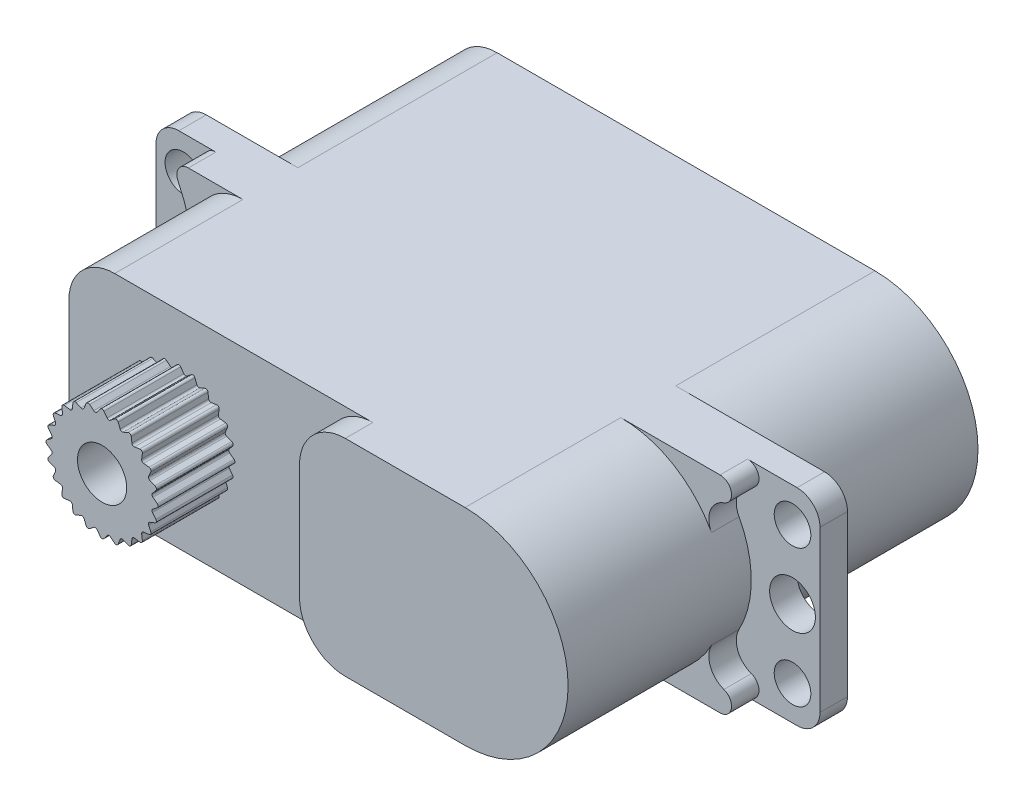
from build123d import *

# Parameters (mm, degrees)
SKETCH_1_W                    = 29
SKETCH_1_H                    = 17.9
EXTRUDE_1_DEPTH               = 9
CUT_EXTRUDE_1_DEPTH           = 8
SKETCH_3_W                    = 3
SKETCH_3_H                    = 8
CUT_EXTRUDE_2_DEPTH           = 10
EXTRUDE_2_DEPTH               = 1.2
EXTRUDE_3_DEPTH               = 1.2
EXTRUDE_4_DEPTH               = 1.2
EXTRUDE_5_DEPTH               = 1.2
SKETCH_8_W                    = 11.270245309
SKETCH_8_H                    = 1.2
CUT_EXTRUDE_3_DEPTH           = 10
CUT_EXTRUDE_4_DEPTH           = 8.7
SKETCH_10_W                   = 3
SKETCH_10_H                   = 8.7
CUT_EXTRUDE_5_DEPTH           = 10
EXTRUDE_6_DEPTH               = 3.35
HOLE_WIZARD_4_9_4_9_1_D       = 4.9
HOLE_WIZARD_4_9_4_9_1_DEPTH   = 8.7
HOLE_WIZARD_2_0_2_1_D         = 2
HOLE_WIZARD_2_0_2_1_DEPTH     = 11.35
HOLE_WIZARD_1_6_1_6_1_D       = 1.6
HOLE_WIZARD_1_6_1_6_1_DEPTH   = 11.35
HOLE_WIZARD_2_15_2_15_1_D     = 2.15
HOLE_WIZARD_2_15_2_15_1_DEPTH = 4.05
HOLE_WIZARD_2_15_2_15_1_TIP   = 0.645925165
FILLET_1_R                    = 0.1
FILLET_2_R                    = 1
FILLET_3_R                    = 2


with BuildPart() as part:
    # 草图1 → 凸台-拉伸1 (new body)
    with BuildSketch(Plane(origin=(0, 4.5, 0), x_dir=(1, 0, 0), z_dir=(0, 1, 0))):
        with Locations((6.7, 0.95)):
            Rectangle(SKETCH_1_W, SKETCH_1_H)
    extrude(amount=-EXTRUDE_1_DEPTH)

    # 草图2 → 切除-拉伸1 (cut)
    with BuildSketch(Plane.XY.offset(8)):
        with BuildLine():
            Line((13.7, -4.5), (21.2, -4.5))
            Line((21.2, -4.5), (21.2, 4.5))
            Line((21.2, 4.5), (13.7, 4.5))
            ThreePointArc((13.7, 4.5), (18.2, 0), (13.7, -4.5))
        make_face()
    extrude(amount=-CUT_EXTRUDE_1_DEPTH, mode=Mode.SUBTRACT)

    # 草图3 → 切除-拉伸2 (cut, through all)
    with BuildSketch(Plane(origin=(0, 4.5, 0), x_dir=(-1, 0, 0), z_dir=(0, 1, 0))):
        with Locations((6.3, 4)):
            Rectangle(SKETCH_3_W, SKETCH_3_H)
    extrude(amount=-CUT_EXTRUDE_2_DEPTH, mode=Mode.SUBTRACT)

    # 草图4 → 凸台-拉伸2 (add)
    with BuildSketch(Plane.XY):
        with BuildLine():
            Line((-4.8, 4.5), (-4.8, 0.09919776))
            ThreePointArc((-4.8, 0.09919776), (-5.011332605, 1.988549506), (-5.634884808, 3.78451558))
            ThreePointArc((-5.634884808, 3.78451558), (-5.606632964, 4.266700009), (-5.183701403, 4.5))
            Line((-5.183701403, 4.5), (-4.8, 4.5))
        make_face()
    extrude(amount=EXTRUDE_2_DEPTH)

    # 草图5 → 凸台-拉伸3 (add)
    with BuildSketch(Plane.XY):
        with BuildLine():
            Line((13.7, 4.5), (18.036138266, 4.5))
            ThreePointArc((18.036138266, 4.5), (18.528949615, 4.084480614), (18.202670288, 3.528547897))
            ThreePointArc((18.202670288, 3.528547897), (17.611520628, 2.954458719), (17.662886698, 2.132024629))
            ThreePointArc((17.662886698, 2.132024629), (16.008234083, 3.862907637), (13.7, 4.5))
        make_face()
    extrude(amount=EXTRUDE_3_DEPTH)

    # 草图6 → 凸台-拉伸4 (add)
    with BuildSketch(Plane.XY):
        with BuildLine():
            Line((18.036138266, -4.5), (13.7, -4.5))
            ThreePointArc((13.7, -4.5), (16.008234083, -3.862907637), (17.662886698, -2.132024629))
            ThreePointArc((17.662886698, -2.132024629), (17.611520628, -2.954458719), (18.202670288, -3.528547897))
            ThreePointArc((18.202670288, -3.528547897), (18.528949615, -4.084480614), (18.036138266, -4.5))
        make_face()
    extrude(amount=EXTRUDE_4_DEPTH)

    # 草图7 → 凸台-拉伸5 (add)
    with BuildSketch(Plane.XY):
        with BuildLine():
            Line((-4.8, -0.09919776), (-4.8, -4.5))
            Line((-4.8, -4.5), (-5.183701403, -4.5))
            ThreePointArc((-5.183701403, -4.5), (-5.606632964, -4.266700009), (-5.634884808, -3.78451558))
            ThreePointArc((-5.634884808, -3.78451558), (-5.011332605, -1.988549506), (-4.8, -0.09919776))
        make_face()
    extrude(amount=EXTRUDE_5_DEPTH)

    # 草图8 → 切除-拉伸3 (cut, through all)
    with BuildSketch(Plane.XZ.offset(4.5)):
        with Locations((0.835122654, 7.4)):
            Rectangle(SKETCH_8_W, SKETCH_8_H)
    extrude(amount=-CUT_EXTRUDE_3_DEPTH, mode=Mode.SUBTRACT)

    # 草图9 → 切除-拉伸4 (cut)
    with BuildSketch(Plane(origin=(0, 0, -9.9), x_dir=(-1, 0, 0), z_dir=(0, 0, -1))):
        with BuildLine():
            Line((-21.2, -4.5), (-13.7, -4.5))
            ThreePointArc((-13.7, -4.5), (-18.2, 0), (-13.7, 4.5))
            Line((-13.7, 4.5), (-21.2, 4.5))
            Line((-21.2, 4.5), (-21.2, -4.5))
        make_face()
    extrude(amount=-CUT_EXTRUDE_4_DEPTH, mode=Mode.SUBTRACT)

    # 草图10 → 切除-拉伸5 (cut, through all)
    with BuildSketch(Plane.XZ.offset(4.5)):
        with Locations((-6.3, -5.55)):
            Rectangle(SKETCH_10_W, SKETCH_10_H)
    extrude(amount=-CUT_EXTRUDE_5_DEPTH, mode=Mode.SUBTRACT)

    # 草图11 → 凸台-拉伸6 (add)
    with BuildSketch(Plane.XY.offset(6.8)):
        with BuildLine():
            Line((1.760594991, 1.646869689), (1.71044478, 1.312470441))
            Line((1.71044478, 1.312470441), (2.04642948, 1.274362931))
            ThreePointArc((2.04642948, 1.274362931), (2.121762239, 1.225), (2.126845412, 1.135078451))
            Line((2.126845412, 1.135078451), (1.991855134, 0.825053411))
            Line((1.991855134, 0.825053411), (2.306528483, 0.701285143))
            ThreePointArc((2.306528483, 0.701285143), (2.366518274, 0.634106661), (2.348154832, 0.545933492))
            Line((2.348154832, 0.545933492), (2.137523852, 0.281410354))
            Line((2.137523852, 0.281410354), (2.409441382, 0.080415932))
            ThreePointArc((2.409441382, 0.080415932), (2.45, 0), (2.409441382, -0.080415932))
            Line((2.409441382, -0.080415932), (2.137523852, -0.281410354))
            Line((2.137523852, -0.281410354), (2.348154832, -0.545933492))
            ThreePointArc((2.348154832, -0.545933492), (2.366518274, -0.634106661), (2.306528483, -0.701285143))
            Line((2.306528483, -0.701285143), (1.991855134, -0.825053411))
            Line((1.991855134, -0.825053411), (2.126845412, -1.135078451))
            ThreePointArc((2.126845412, -1.135078451), (2.121762239, -1.225), (2.04642948, -1.274362931))
            Line((2.04642948, -1.274362931), (1.71044478, -1.312470441))
            Line((1.71044478, -1.312470441), (1.760594991, -1.646869689))
            ThreePointArc((1.760594991, -1.646869689), (1.732411614, -1.732411614), (1.646869689, -1.760594991))
            Line((1.646869689, -1.760594991), (1.312470441, -1.71044478))
            Line((1.312470441, -1.71044478), (1.274362931, -2.04642948))
            ThreePointArc((1.274362931, -2.04642948), (1.225, -2.121762239), (1.135078451, -2.126845412))
            Line((1.135078451, -2.126845412), (0.825053411, -1.991855134))
            Line((0.825053411, -1.991855134), (0.701285143, -2.306528483))
            ThreePointArc((0.701285143, -2.306528483), (0.634106661, -2.366518274), (0.545933492, -2.348154832))
            Line((0.545933492, -2.348154832), (0.281410354, -2.137523852))
            Line((0.281410354, -2.137523852), (0.080415932, -2.409441382))
            ThreePointArc((0.080415932, -2.409441382), (0, -2.45), (-0.080415932, -2.409441382))
            Line((-0.080415932, -2.409441382), (-0.281410354, -2.137523852))
            Line((-0.281410354, -2.137523852), (-0.545933492, -2.348154832))
            ThreePointArc((-0.545933492, -2.348154832), (-0.634106661, -2.366518274), (-0.701285143, -2.306528483))
            Line((-0.701285143, -2.306528483), (-0.825053411, -1.991855134))
            Line((-0.825053411, -1.991855134), (-1.135078451, -2.126845412))
            ThreePointArc((-1.135078451, -2.126845412), (-1.225, -2.121762239), (-1.274362931, -2.04642948))
            Line((-1.274362931, -2.04642948), (-1.312470441, -1.71044478))
            Line((-1.312470441, -1.71044478), (-1.646869689, -1.760594991))
            ThreePointArc((-1.646869689, -1.760594991), (-1.732411614, -1.732411614), (-1.760594991, -1.646869689))
            Line((-1.760594991, -1.646869689), (-1.71044478, -1.312470441))
            Line((-1.71044478, -1.312470441), (-2.04642948, -1.274362931))
            ThreePointArc((-2.04642948, -1.274362931), (-2.121762239, -1.225), (-2.126845412, -1.135078451))
            Line((-2.126845412, -1.135078451), (-1.991855134, -0.825053411))
            Line((-1.991855134, -0.825053411), (-2.306528483, -0.701285143))
            ThreePointArc((-2.306528483, -0.701285143), (-2.366518274, -0.634106661), (-2.348154832, -0.545933492))
            Line((-2.348154832, -0.545933492), (-2.137523852, -0.281410354))
            Line((-2.137523852, -0.281410354), (-2.409441382, -0.080415932))
            ThreePointArc((-2.409441382, -0.080415932), (-2.45, 0), (-2.409441382, 0.080415932))
            Line((-2.409441382, 0.080415932), (-2.137523852, 0.281410354))
            Line((-2.137523852, 0.281410354), (-2.348154832, 0.545933492))
            ThreePointArc((-2.348154832, 0.545933492), (-2.366518274, 0.634106661), (-2.306528483, 0.701285143))
            Line((-2.306528483, 0.701285143), (-1.991855134, 0.825053411))
            Line((-1.991855134, 0.825053411), (-2.126845412, 1.135078451))
            ThreePointArc((-2.126845412, 1.135078451), (-2.121762239, 1.225), (-2.04642948, 1.274362931))
            Line((-2.04642948, 1.274362931), (-1.71044478, 1.312470441))
            Line((-1.71044478, 1.312470441), (-1.760594991, 1.646869689))
            ThreePointArc((-1.760594991, 1.646869689), (-1.732411614, 1.732411614), (-1.646869689, 1.760594991))
            Line((-1.646869689, 1.760594991), (-1.312470441, 1.71044478))
            Line((-1.312470441, 1.71044478), (-1.274362931, 2.04642948))
            ThreePointArc((-1.274362931, 2.04642948), (-1.225, 2.121762239), (-1.135078451, 2.126845412))
            Line((-1.135078451, 2.126845412), (-0.825053411, 1.991855134))
            Line((-0.825053411, 1.991855134), (-0.701285143, 2.306528483))
            ThreePointArc((-0.701285143, 2.306528483), (-0.634106661, 2.366518274), (-0.545933492, 2.348154832))
            Line((-0.545933492, 2.348154832), (-0.281410354, 2.137523852))
            Line((-0.281410354, 2.137523852), (-0.080415932, 2.409441382))
            ThreePointArc((-0.080415932, 2.409441382), (0, 2.45), (0.080415932, 2.409441382))
            Line((0.080415932, 2.409441382), (0.281410354, 2.137523852))
            Line((0.281410354, 2.137523852), (0.545933492, 2.348154832))
            ThreePointArc((0.545933492, 2.348154832), (0.634106661, 2.366518274), (0.701285143, 2.306528483))
            Line((0.701285143, 2.306528483), (0.825053411, 1.991855134))
            Line((0.825053411, 1.991855134), (1.135078451, 2.126845412))
            ThreePointArc((1.135078451, 2.126845412), (1.225, 2.121762239), (1.274362931, 2.04642948))
            Line((1.274362931, 2.04642948), (1.312470441, 1.71044478))
            Line((1.312470441, 1.71044478), (1.646869689, 1.760594991))
            ThreePointArc((1.646869689, 1.760594991), (1.732411614, 1.732411614), (1.760594991, 1.646869689))
        make_face()
    extrude(amount=EXTRUDE_6_DEPTH)

    # Ø4.9 (4.9) 直径孔1
    with Locations(Plane(origin=(0, 0, -9.9), x_dir=(-1, 0, 0), z_dir=(0, 0, -1))):
        with Locations((0, 0)):
            Hole(HOLE_WIZARD_4_9_4_9_1_D / 2, depth=HOLE_WIZARD_4_9_4_9_1_DEPTH)

    # Ø2.0 (2) 直径孔1
    with Locations(Plane(origin=(0, 0, -1.2), x_dir=(-1, 0, 0), z_dir=(0, 0, -1))):
        with Locations((6.6, 0), (-20, 0)):
            Hole(HOLE_WIZARD_2_0_2_1_D / 2, depth=HOLE_WIZARD_2_0_2_1_DEPTH)

    # Ø1.6 (1.6) 直径孔1
    with Locations(Plane(origin=(0, 0, -1.2), x_dir=(-1, 0, 0), z_dir=(0, 0, -1))):
        with Locations((6.6, -3), (6.6, 3), (-20, -3), (-20, 3)):
            Hole(HOLE_WIZARD_1_6_1_6_1_D / 2, depth=HOLE_WIZARD_1_6_1_6_1_DEPTH)

    # Ø2.15 (2.15) 直径孔1
    with Locations(Plane.XY.offset(10.15)):
        with Locations((0, 0)):
            Hole(HOLE_WIZARD_2_15_2_15_1_D / 2, depth=HOLE_WIZARD_2_15_2_15_1_DEPTH)
            with Locations((0, 0, -(HOLE_WIZARD_2_15_2_15_1_DEPTH + HOLE_WIZARD_2_15_2_15_1_TIP / 2))):  # 118° drill point
                Cone(0, HOLE_WIZARD_2_15_2_15_1_D / 2, HOLE_WIZARD_2_15_2_15_1_TIP, mode=Mode.SUBTRACT)

    # 圆角1
    fillet_1_edges = [part.edges().sort_by_distance(p)[0] for p in [
        (1.312470441, 1.71044478, 8.475),
        (0.825053411, 1.991855134, 8.475),
        (0.281410354, 2.137523852, 8.475),
        (-0.281410354, 2.137523852, 8.475),
        (-0.825053411, 1.991855134, 8.475),
        (-1.312470441, 1.71044478, 8.475),
        (-1.71044478, 1.312470441, 8.475),
        (-1.991855134, 0.825053411, 8.475),
        (-2.137523852, 0.281410354, 8.475),
        (-2.137523852, -0.281410354, 8.475),
        (-1.991855134, -0.825053411, 8.475),
        (-1.71044478, -1.312470441, 8.475),
        (-1.312470441, -1.71044478, 8.475),
        (-0.825053411, -1.991855134, 8.475),
        (-0.281410354, -2.137523852, 8.475),
        (0.281410354, -2.137523852, 8.475),
        (0.825053411, -1.991855134, 8.475),
        (1.312470441, -1.71044478, 8.475),
        (1.71044478, -1.312470441, 8.475),
        (1.991855134, -0.825053411, 8.475),
        (2.137523852, -0.281410354, 8.475),
        (2.137523852, 0.281410354, 8.475),
        (1.991855134, 0.825053411, 8.475),
        (1.71044478, 1.312470441, 8.475),
    ]]
    fillet(fillet_1_edges, radius=FILLET_1_R)

    # 圆角2
    fillet_2_edges = [part.edges().sort_by_distance(p)[0] for p in [
        (-7.8, 4.5, -0.6),
        (-7.8, -4.5, -0.6),
        (21.2, 4.5, -0.6),
        (21.2, -4.5, -0.6),
    ]]
    fillet(fillet_2_edges, radius=FILLET_2_R)

    # 圆角3
    fillet_3_edges = [part.edges().sort_by_distance(p)[0] for p in [
        (-4.8, -4.5, 4),
        (6.470245309, 4.5, 7.4),
        (6.470245309, -4.5, 7.4),
        (-4.8, 4.5, -5.55),
        (-4.8, -4.5, -5.55),
        (-4.8, 4.5, 4),
    ]]
    fillet(fillet_3_edges, radius=FILLET_3_R)


solid = part.part
